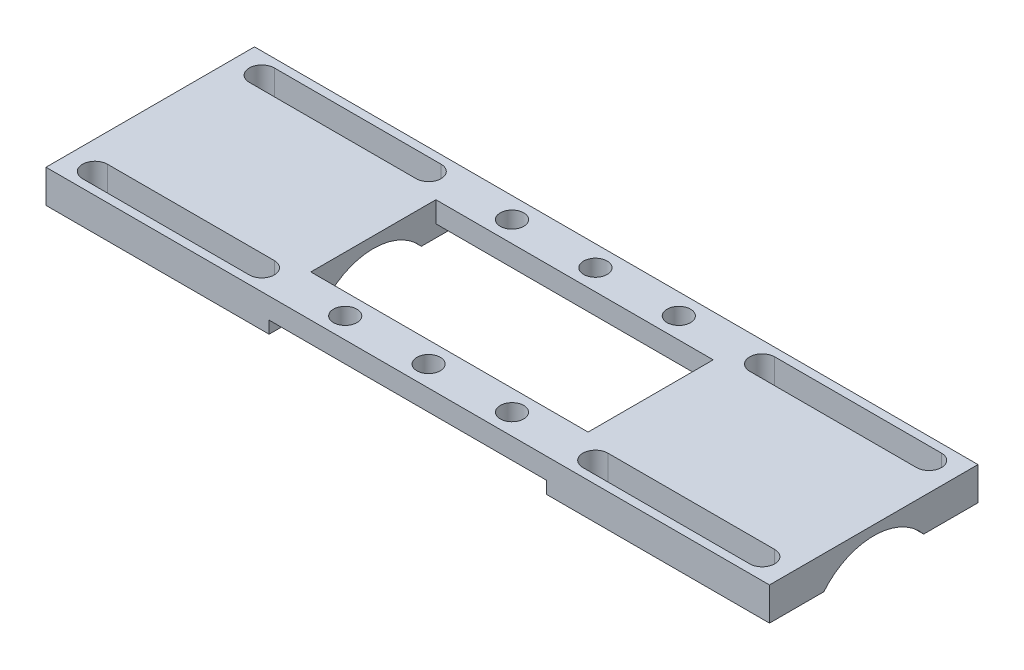
from build123d import *

# Parameters (mm, degrees)
SKETCH3_W            = 42.8
SKETCH3_H            = 40
BOSS_EXTRUDE1_DEPTH  = 6.35
SKETCH4_R            = 12.4
CUT_EXTRUDE1_DEPTH   = 12.8
SKETCH5_R            = 12.115
CUT_EXTRUDE2_DEPTH   = 31
SKETCH6_W            = 8
SKETCH6_H            = 4
BOSS_EXTRUDE2_DEPTH  = 53.2
SKETCH7_R            = 2.25
CUT_EXTRUDE3_DEPTH   = 4
LPATTERN1_COUNT      = 3
LPATTERN1_PITCH      = 16
LPATTERN1_COUNT_DIR2 = 2
LPATTERN1_PITCH_DIR2 = 32


with BuildPart() as part:
    # Sketch3 → Boss-Extrude1 (new body)
    with BuildSketch(Plane(origin=(0, 0, 0), x_dir=(1, 0, 0), z_dir=(0, 1, 0))):
        with Locations((48, 0)):
            Rectangle(SKETCH3_W, SKETCH3_H)
        with BuildLine():
            Line((32, 18.4), (64, 18.4))
            ThreePointArc((64, 18.4), (66.4, 16), (64, 13.6))
            Line((64, 13.6), (32, 13.6))
            ThreePointArc((32, 13.6), (29.6, 16), (32, 18.4))
        make_face(mode=Mode.SUBTRACT)
        with BuildLine():
            Line((32, -18.4), (64, -18.4))
            ThreePointArc((64, -18.4), (66.4, -16), (64, -13.6))
            Line((64, -13.6), (32, -13.6))
            ThreePointArc((32, -13.6), (29.6, -16), (32, -18.4))
        make_face(mode=Mode.SUBTRACT)
    extrude(amount=BOSS_EXTRUDE1_DEPTH)

    # Sketch4 → Cut-Extrude1 (cut)
    with BuildSketch(Plane(origin=(69.4, 0, 0), x_dir=(0, 0, -1), z_dir=(1, 0, 0))):
        with Locations((0, -7.874)):
            Circle(SKETCH4_R)
    extrude(amount=-CUT_EXTRUDE1_DEPTH, mode=Mode.SUBTRACT)

    # Sketch5 → Cut-Extrude2 (cut, through all)
    with BuildSketch(Plane(origin=(56.6, 0, 0), x_dir=(0, 0, -1), z_dir=(1, 0, 0))):
        with Locations((0, -7.874)):
            Circle(SKETCH5_R)
    extrude(amount=-CUT_EXTRUDE2_DEPTH, mode=Mode.SUBTRACT)


with BuildPart() as body_2:
    # Mirror2: mirrored copy
    add(part.part.mirror(Plane(origin=(0, 0, 0), x_dir=(0, 0, 1), z_dir=(1, 0, 0))))


with BuildPart() as part_1:
    add(part.part)

    add(body_2.part)  # Boss-Extrude2 merges body 2
    # Sketch6 → Boss-Extrude2 (add)
    with BuildSketch(Plane.ZY.offset(-26.6)):
        with Locations((-16, 4.35)):
            Rectangle(SKETCH6_W, SKETCH6_H)
        with Locations((16, 4.35)):
            Rectangle(SKETCH6_W, SKETCH6_H)
    extrude(amount=BOSS_EXTRUDE2_DEPTH)

    # Sketch7 → Cut-Extrude3 (cut)
    with BuildSketch(Plane(origin=(0, 6.35, 0), x_dir=(1, 0, 0), z_dir=(0, 1, 0))):
        with Locations((-16, 16)):
            Circle(SKETCH7_R)
    cut_extrude3 = extrude(amount=-CUT_EXTRUDE3_DEPTH, mode=Mode.SUBTRACT)

    # LPattern1: Cut-Extrude3 3 × 2
    with Locations(*[(i * LPATTERN1_PITCH, 0, j * LPATTERN1_PITCH_DIR2) for i in range(LPATTERN1_COUNT) for j in range(LPATTERN1_COUNT_DIR2) if (i, j) != (0, 0)]):
        add(cut_extrude3, mode=Mode.SUBTRACT)


solid = part_1.part
